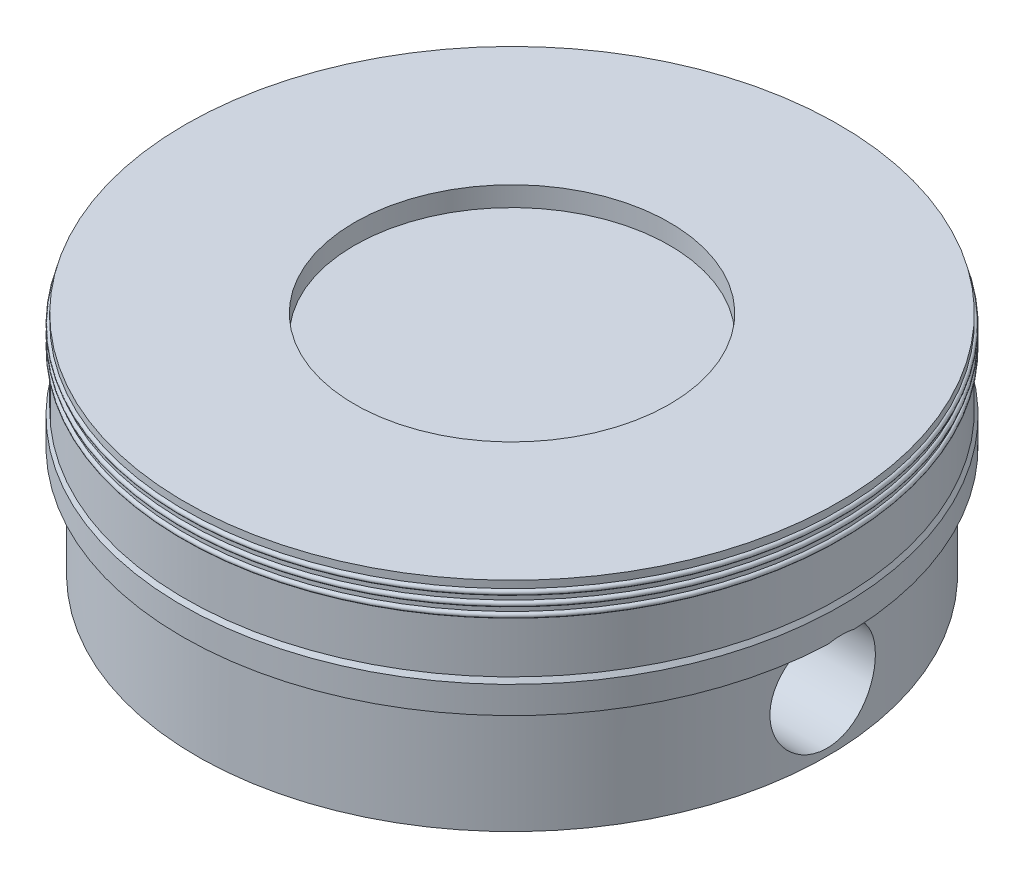
from build123d import *

# Parameters (mm, degrees)
BOSS_EXTRUDE2_REACH     = 5.43
SKETCH4_R               = 0.8
CUT_EXTRUDE1_DEPTH      = 6.0000001
CUT_EXTRUDE1_DEPTH_BACK = 6.0000001


with BuildPart() as part:
    # Sketch1 → Revolve1 (revolve)
    with BuildSketch(Plane.XY):
        with BuildLine():
            Line((3.43, 0), (4.78, 0))
            Line((4.78, 0), (4.78, 1.68))
            Line((4.78, 1.68), (5, 1.68))
            Line((5, 1.68), (5, 2.09))
            Line((5, 2.09), (4.96, 2.16))
            Line((4.96, 2.16), (4.96, 2.94))
            ThreePointArc((4.96, 2.94), (5, 2.98), (4.96, 3.02))
            Line((4.96, 3.02), (4.96, 3.09))
            ThreePointArc((4.96, 3.09), (5, 3.13), (4.96, 3.17))
            Line((4.96, 3.17), (4.96, 3.24))
            ThreePointArc((4.96, 3.24), (5, 3.28), (4.96, 3.32))
            Line((4.96, 3.32), (4.96, 3.43))
            Line((4.96, 3.43), (2.39, 3.43))
            Line((2.39, 3.43), (2.39, 3.13))
            Line((2.39, 3.13), (0, 3.13))
            Line((0, 3.13), (0, 2.33))
            Line((0, 2.33), (4.2, 2.33))
            Line((4.2, 2.33), (4.2, 1.93))
            Line((4.2, 1.93), (3.43, 1.93))
            Line((3.43, 1.93), (3.43, 0))
        make_face()
    revolve(axis=Axis((0, 3, 0), (0, -1, 0)))

    # Sketch3 → Boss-Extrude2 (add, up to next)
    with BuildSketch(Plane.XZ, mode=Mode.PRIVATE) as boss_extrude2_sk1:
        with BuildLine():
            Line((-1.75, 2.949983051), (-1.75, -2.949983051))
            ThreePointArc((-1.75, -2.949983051), (-3.43, 0), (-1.75, 2.949983051))
        make_face()
    boss_extrude2_tool1 = extrude(boss_extrude2_sk1.sketch, amount=-BOSS_EXTRUDE2_REACH, mode=Mode.PRIVATE) - part.part
    add(boss_extrude2_tool1.solids().sort_by_distance((-2.438465, 0, 0))[0])
    # Sketch3 → Boss-Extrude2 (add, up to next)
    with BuildSketch(Plane.XZ, mode=Mode.PRIVATE) as boss_extrude2_sk2:
        with BuildLine():
            Line((1.75, 2.949983051), (1.75, -2.949983051))
            ThreePointArc((1.75, -2.949983051), (3.43, 0), (1.75, 2.949983051))
        make_face()
    boss_extrude2_tool2 = extrude(boss_extrude2_sk2.sketch, amount=-BOSS_EXTRUDE2_REACH, mode=Mode.PRIVATE) - part.part
    add(boss_extrude2_tool2.solids().sort_by_distance((2.438465, 0, 0))[0])

    # Sketch4 → Cut-Extrude1 (cut, two sides)
    with BuildSketch(Plane(origin=(0, 0, 0), x_dir=(0, 0, -1), z_dir=(1, 0, 0))) as cut_extrude1_sk:
        with Locations((0, 0.9065)):
            Circle(SKETCH4_R)
    extrude(amount=CUT_EXTRUDE1_DEPTH, mode=Mode.SUBTRACT)
    extrude(cut_extrude1_sk.sketch, amount=-CUT_EXTRUDE1_DEPTH_BACK, mode=Mode.SUBTRACT)


solid = part.part
